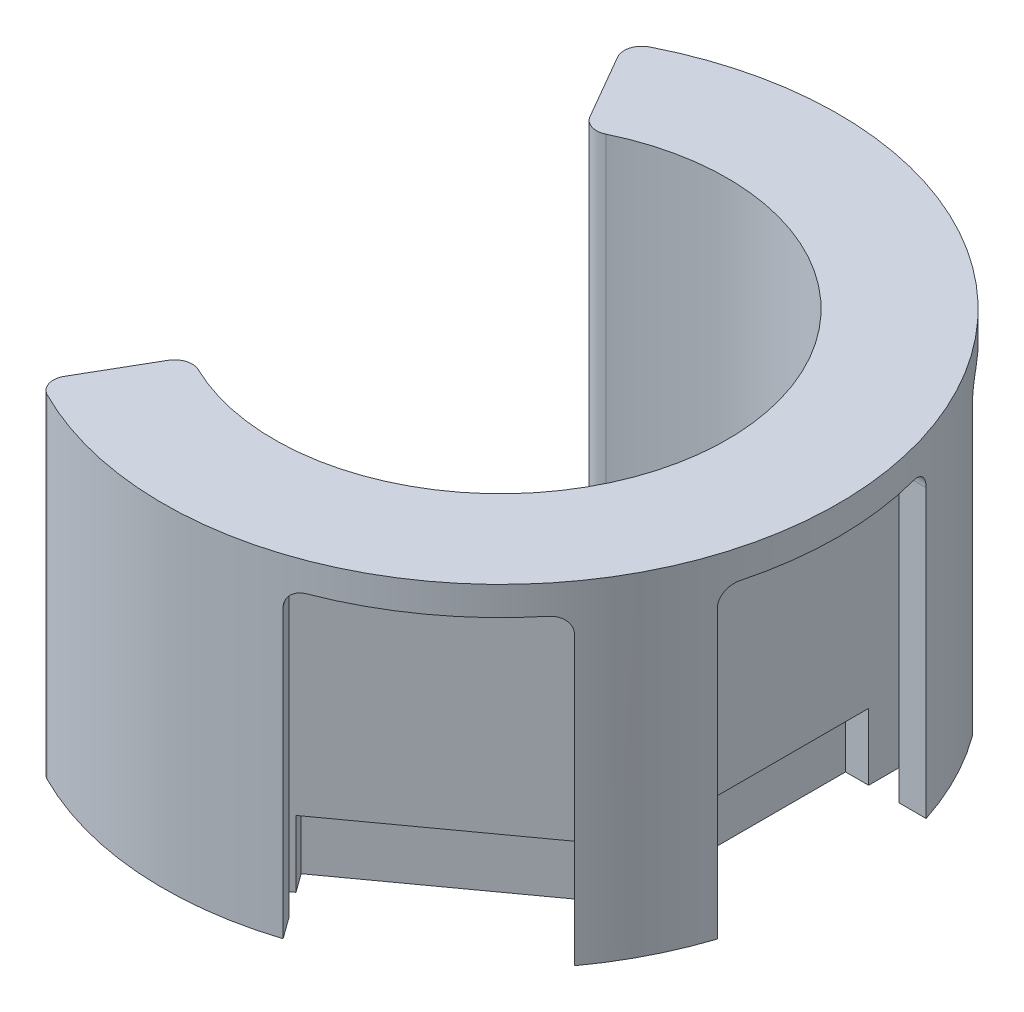
from build123d import *

# Parameters (mm, degrees)
SKETCH1_R           = 48.26
SKETCH1_R_2         = 32.385
BOSS_EXTRUDE1_DEPTH = 47.625
CUT_EXTRUDE2_START  = -43.50766
CUT_EXTRUDE2_DEPTH  = 43.50766
SKETCH3_W           = 4.572
SKETCH3_H           = 29.845
CUT_EXTRUDE3_DEPTH  = 9.525
SKETCH4_W           = 29.845
SKETCH4_H           = 43.50766
CUT_EXTRUDE4_DEPTH  = 26.400930862
SKETCH5_W           = 29.845
SKETCH5_H           = 43.50766
CUT_EXTRUDE5_DEPTH  = 7.273566766
SKETCH6_W           = 29.845
SKETCH6_H           = 43.50766
CUT_EXTRUDE6_DEPTH  = 26.400930862
CUT_EXTRUDE7_DEPTH  = 48.625
FILLET1_R           = 2.54
FILLET2_R           = 2.54


with BuildPart() as part:
    # Sketch1 → Boss-Extrude1 (new body)
    with BuildSketch(Plane(origin=(0, -40.33266, 0), x_dir=(1, 0, 0), z_dir=(0, 1, 0))):
        Circle(SKETCH1_R)
        Circle(SKETCH1_R_2, mode=Mode.SUBTRACT)
    extrude(amount=BOSS_EXTRUDE1_DEPTH)

    # Sketch2 → Cut-Extrude2 (cut)
    with BuildSketch(Plane.XZ.offset(40.33266).offset(CUT_EXTRUDE2_START)):
        Polygon((40.557916835, -22.48144085), (8.658940442, -45.556366746), (6.128142118, -42.057769336), (37.668433234, -19.242307445), (37.668433234, 19.242307445), (6.128142118, 42.057769336), (8.658940442, 45.556366746), (40.557916835, 22.48144085), (38.535041098, 19.685), (41.986433234, 19.685), (41.986433234, -19.685), (38.535041098, -19.685), align=None)
    extrude(amount=CUT_EXTRUDE2_DEPTH, mode=Mode.SUBTRACT)

    # Sketch3 → Cut-Extrude3 (cut)
    with BuildSketch(Plane(origin=(0, -40.33266, 0), x_dir=(1, 0, 0), z_dir=(0, 1, 0))):
        Polygon((10.731241711, 40.295446893), (8.051572897, 36.591049635), (32.233055001, 19.098767101), (34.912723815, 22.803164359), align=None)
        with Locations((36.652433234, 0)):
            Rectangle(SKETCH3_W, SKETCH3_H)
        Polygon((32.233055001, -19.098767101), (8.051572897, -36.591049635), (10.731241711, -40.295446893), (34.912723815, -22.803164359), align=None)
    extrude(amount=CUT_EXTRUDE3_DEPTH, mode=Mode.SUBTRACT)

    # Sketch4 → Cut-Extrude4 (cut, through all)
    with BuildSketch(Plane(origin=(24.608428639, 0, -34.018903798), x_dir=(0.810235621, 0, 0.58610429), z_dir=(-0.58610429, 0, 0.810235621))):
        with Locations((0, -18.57883)):
            Rectangle(SKETCH4_W, SKETCH4_H)
    extrude(amount=-CUT_EXTRUDE4_DEPTH, mode=Mode.SUBTRACT)

    # Sketch5 → Cut-Extrude5 (cut, through all)
    with BuildSketch(Plane.ZY.offset(-41.986433234)):
        with Locations((0, -18.57883)):
            Rectangle(SKETCH5_W, SKETCH5_H)
    extrude(amount=-CUT_EXTRUDE5_DEPTH, mode=Mode.SUBTRACT)

    # Sketch6 → Cut-Extrude6 (cut, through all)
    with BuildSketch(Plane(origin=(24.608428639, 0, 34.018903798), x_dir=(-0.810235621, 0, 0.58610429), z_dir=(-0.58610429, 0, -0.810235621))):
        with Locations((0, -18.57883)):
            Rectangle(SKETCH6_W, SKETCH6_H)
    extrude(amount=-CUT_EXTRUDE6_DEPTH, mode=Mode.SUBTRACT)

    # Sketch7 → Cut-Extrude7 (cut, through all)
    with BuildSketch(Plane.XZ.offset(40.33266)):
        with BuildLine():
            Line((0, 0), (-24.13, 41.794385987))
            ThreePointArc((-24.13, 41.794385987), (-48.26, 0), (-24.13, -41.794385987))
            Line((-24.13, -41.794385987), (0, 0))
        make_face()
    extrude(amount=-CUT_EXTRUDE7_DEPTH, mode=Mode.SUBTRACT)

    # Fillet1
    fillet1_edges = [part.edges().sort_by_distance(p)[0] for p in [
        (-16.1925, -16.52016, 28.046232702),
        (-16.1925, -16.52016, -28.046232702),
        (-24.13, -16.52016, -41.794385987),
        (-24.13, -16.52016, 41.794385987),
    ]]
    fillet(fillet1_edges, radius=FILLET1_R)

    # Fillet2
    fillet2_edges = [part.edges().sort_by_distance(p)[0] for p in [
        (13.663087314, 3.175, -44.348455518),
        (37.844569418, 3.175, -26.856172984),
        (43.940692479, 3.175, -14.9225),
        (43.940692479, 3.175, 14.9225),
        (37.844569418, 3.175, 26.856172984),
        (13.663087314, 3.175, 44.348455518),
    ]]
    fillet(fillet2_edges, radius=FILLET2_R)


solid = part.part
